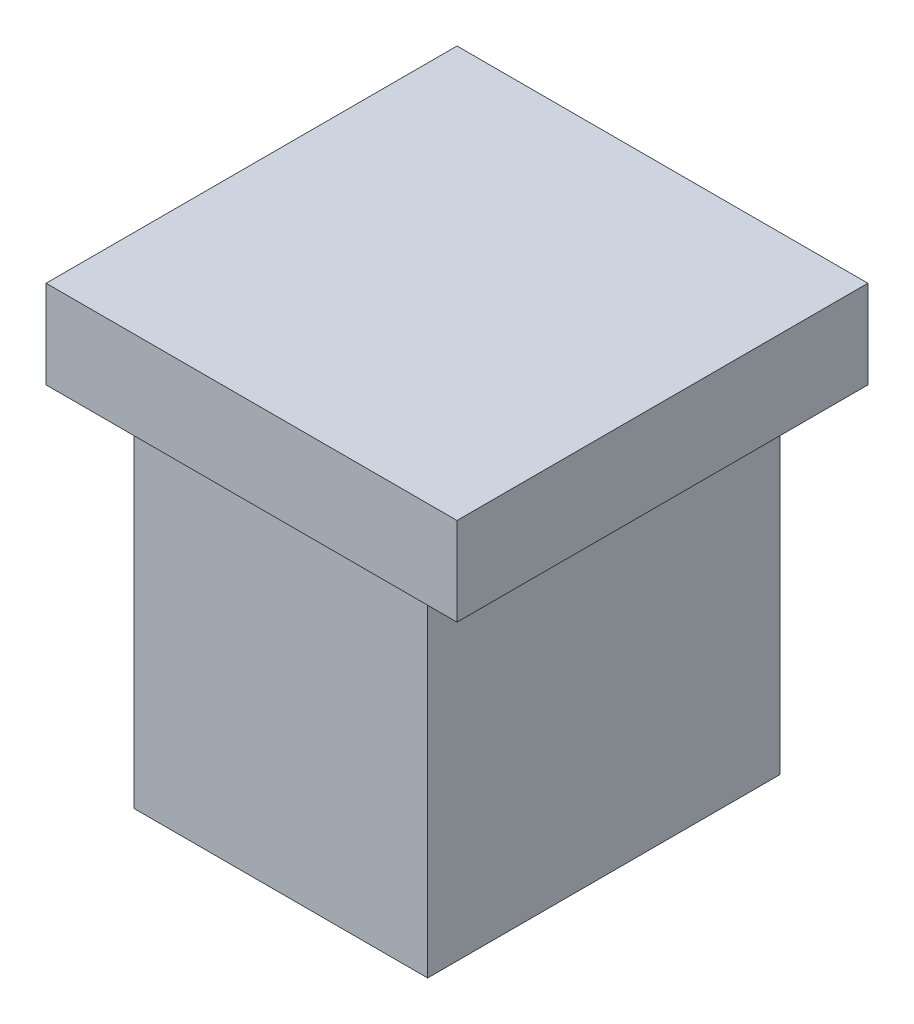
from build123d import *

# Parameters (mm, degrees)
SKETCH_1_W      = 10
SKETCH_1_H      = 12
EXTRUDE_1_DEPTH = 12
EXTRUDE_START   = 12
SKETCH_1_3_W    = 14
SKETCH_1_3_H    = 14
SKETCH_1_3_W_2  = 10
SKETCH_1_3_H_2  = 12
EXTRUDE_2_DEPTH = 3


with BuildPart() as part:
    # Эскиз1 → Бобышка-Вытянуть1 (new body)
    with BuildSketch(Plane(origin=(0, 0, 0), x_dir=(1, 0, 0), z_dir=(0, 1, 0))):
        Rectangle(SKETCH_1_W, SKETCH_1_H)
    extrude(amount=EXTRUDE_1_DEPTH)

    # Эскиз1<3> → Бобышка-Вытянуть2 (add)
    with BuildSketch(Plane(origin=(0, 0, 0), x_dir=(1, 0, 0), z_dir=(0, 1, 0)).offset(EXTRUDE_START)):
        Rectangle(SKETCH_1_3_W, SKETCH_1_3_H)
        Rectangle(SKETCH_1_3_W_2, SKETCH_1_3_H_2, mode=Mode.SUBTRACT)
        Rectangle(SKETCH_1_3_W_2, SKETCH_1_3_H_2)
    extrude(amount=EXTRUDE_2_DEPTH)


solid = part.part
